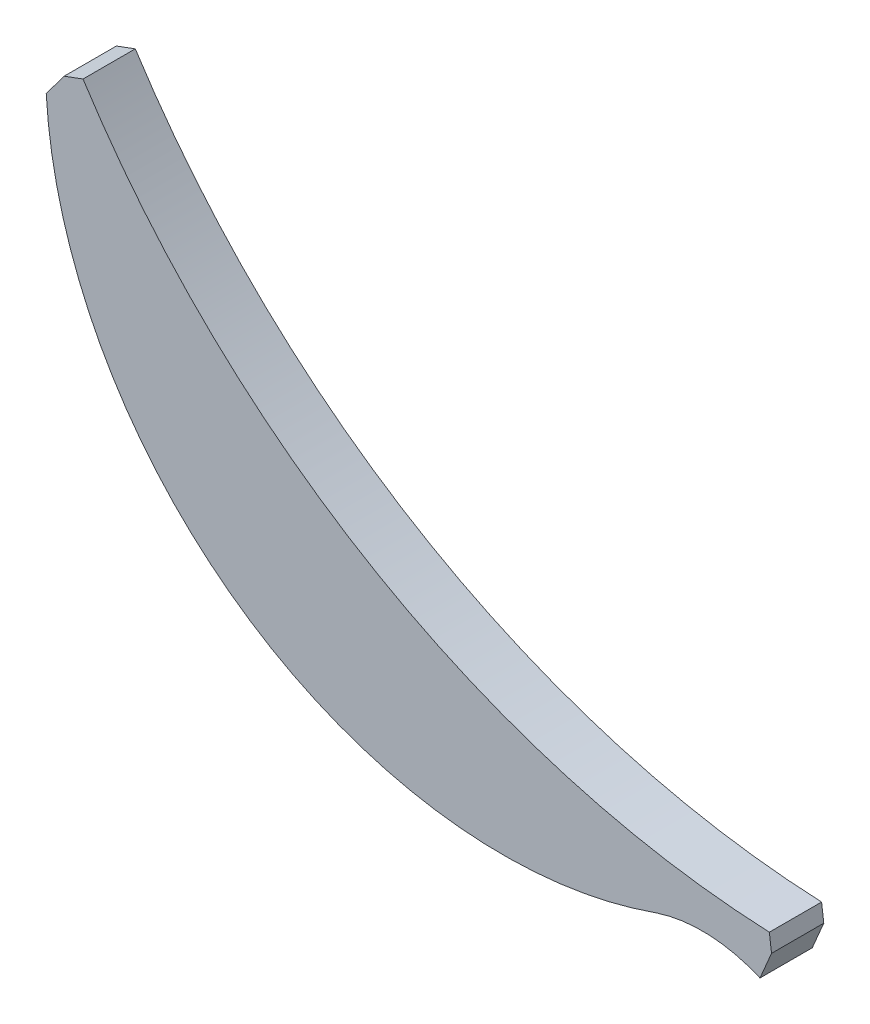
from build123d import *

# Parameters (mm, degrees)
SALIENTE_EXTRUIR1_DEPTH = 3


with BuildPart() as part:
    # Model → Saliente-Extruir1 (new body)
    with BuildSketch(Plane.XY):
        with BuildLine():
            Line((49.555981249, 5.697120887), (50.217934692, 7.253298598))
            Line((50.217934692, 7.253298598), (50.092452983, 8.243189758))
            ThreePointArc((50.092452983, 8.243189758), (27.621595202, 14.792954102), (10.694790748, 30.958415843))
            Line((10.694790748, 30.958415843), (9.611017038, 30.557274304))
            Line((9.611017038, 30.557274304), (8.582065308, 29.179502343))
            ThreePointArc((8.582065308, 29.179502343), (9.359106699, 24.192582613), (11.075472958, 19.446294739))
            ThreePointArc((11.075472958, 19.446294739), (24.748133849, 6.443892033), (43.61000442, 5.960187025))
            ThreePointArc((43.61000442, 5.960187025), (46.607144549, 6.374545334), (49.555981249, 5.697120887))
        make_face()
    extrude(amount=SALIENTE_EXTRUIR1_DEPTH)


solid = part.part
